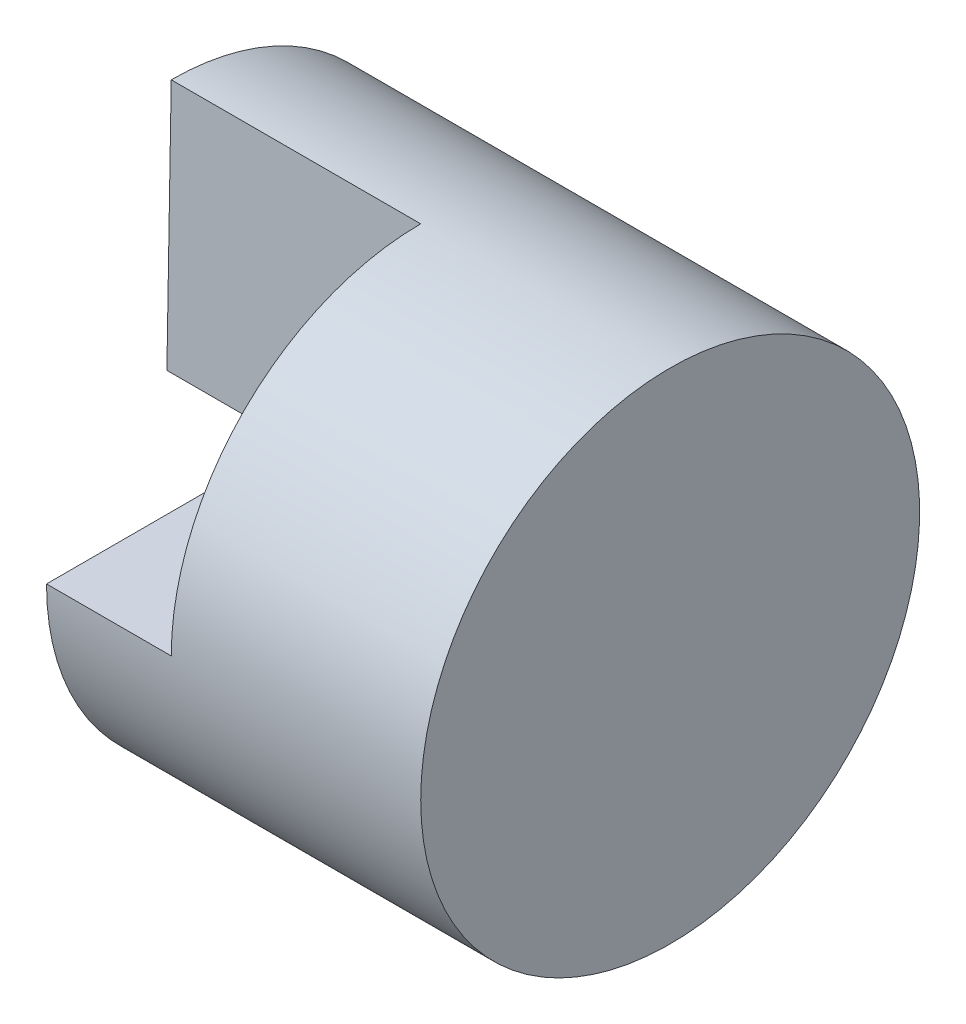
from build123d import *

# Parameters (mm, degrees)
SKETCH5_W           = 4
SKETCH5_H           = 2
SKETCH6_W           = 1
SKETCH6_H           = 2
CUT_EXTRUDE5_DEPTH  = 11
SKETCH8_W           = 0.5
SKETCH8_H           = 2
CUT_EXTRUDE7_DEPTH  = 10
SKETCH9_W           = 1.5
SKETCH9_H           = 2
CUT_EXTRUDE8_DEPTH  = 10
BOSS_EXTRUDE1_DEPTH = 4
SKETCH13_W          = 4.449870591
SKETCH13_H          = 3.198188742
CUT_EXTRUDE10_DEPTH = 1


with BuildPart() as part:
    # Sketch5 → Revolve-Thin2 (revolve)
    with BuildSketch(Plane.XY):
        with Locations((2, 1)):
            Rectangle(SKETCH5_W, SKETCH5_H)
    revolve(axis=Axis((0, 0, 0), (1, 0, 0)))

    # Sketch6 → Cut-Extrude5 (cut)
    with BuildSketch(Plane.XY):
        with Locations((3.5, 1)):
            Rectangle(SKETCH6_W, SKETCH6_H)
        with Locations((0.5, 1)):
            Rectangle(SKETCH6_W, SKETCH6_H)
    extrude(amount=-CUT_EXTRUDE5_DEPTH, mode=Mode.SUBTRACT)

    # Sketch8 → Cut-Extrude7 (cut)
    with BuildSketch(Plane(origin=(0, 0, 0), x_dir=(-1, 0, 0), z_dir=(0, 0, -1))):
        with Locations((-0.25, 1)):
            Rectangle(SKETCH8_W, SKETCH8_H)
    extrude(amount=-CUT_EXTRUDE7_DEPTH, mode=Mode.SUBTRACT)

    # Sketch9 → Cut-Extrude8 (cut)
    with BuildSketch(Plane(origin=(0, 0, 0), x_dir=(-1, 0, 0), z_dir=(0, 0, -1))):
        with Locations((-1.25, 1)):
            Rectangle(SKETCH9_W, SKETCH9_H)
    extrude(amount=-CUT_EXTRUDE8_DEPTH, mode=Mode.SUBTRACT)

    # Sketch10 → Boss-Extrude1 (add)
    with BuildSketch(Plane(origin=(4, 0, 0), x_dir=(0, 0, -1), z_dir=(1, 0, 0))):
        with BuildLine():
            Line((2, 0), (-0.034977088, 0))
            Line((-0.034977088, 0), (0, 2))
            ThreePointArc((0, 2), (1.414213562, 1.414213562), (2, 0))
        make_face()
    extrude(amount=-BOSS_EXTRUDE1_DEPTH)

    # Sketch13 → Cut-Extrude10 (cut)
    with BuildSketch(Plane.ZY):
        with Locations((-0.224935296, -1.599094371)):
            Rectangle(SKETCH13_W, SKETCH13_H)
    extrude(amount=-CUT_EXTRUDE10_DEPTH, mode=Mode.SUBTRACT)


solid = part.part
